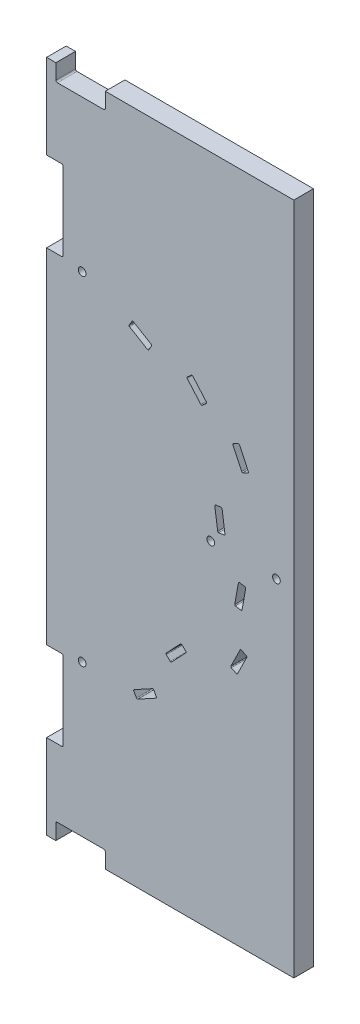
from build123d import *

# Parameters (mm, degrees)
SKETCH1_W                = 160
SKETCH1_H                = 436
BOSS_EXTRUDE1_DEPTH      = 12.7
CUT_EXTRUDE1_DEPTH       = 366.47051465
CIRPATTERN1_COUNT        = 3
CIRPATTERN1_ANGLE        = 102.52
CUT_EXTRUDE2_DEPTH       = 366.47051465
CIRPATTERN2_COUNT        = 2
CIRPATTERN2_ANGLE        = 51.26
F_5_0_5_DIAMETER_HOLE1_D = 5
CUT_EXTRUDE3_DEPTH       = 366.47051465


with BuildPart() as part:
    # Sketch1 → Boss-Extrude1 (new body)
    with BuildSketch(Plane.XY):
        with Locations((74.181489842, 113.112481294)):
            Rectangle(SKETCH1_W, SKETCH1_H)
    extrude(amount=BOSS_EXTRUDE1_DEPTH)

    # Sketch3 → Cut-Extrude1 (cut, through all)
    with BuildSketch(Plane(origin=(0, 0, 0), x_dir=(-1, 0, 0), z_dir=(0, 0, -1))):
        with BuildLine():
            Line((-59.468207995, 200.039680409), (-47.878421887, 206.962603057))
            ThreePointArc((-47.878421887, 206.962603057), (-47.604309032, 207.331039293), (-47.671005734, 207.785390113))
            Line((-47.671005734, 207.785390113), (-49.508913494, 210.862263699))
            ThreePointArc((-49.508913494, 210.862263699), (-49.87734973, 211.136376554), (-50.33170055, 211.069679852))
            Line((-50.33170055, 211.069679852), (-61.921486657, 204.146757205))
            ThreePointArc((-61.921486657, 204.146757205), (-62.195599513, 203.778320969), (-62.128902811, 203.323970149))
            Line((-62.128902811, 203.323970149), (-60.29099505, 200.247096563))
            ThreePointArc((-60.29099505, 200.247096563), (-59.922558815, 199.972983708), (-59.468207995, 200.039680409))
        make_face()
        with BuildLine():
            Line((-94.041533827, 186.486629291), (-85.165935337, 196.658834137))
            ThreePointArc((-85.165935337, 196.658834137), (-85.019418624, 197.094053588), (-85.223562287, 197.505403175))
            Line((-85.223562287, 197.505403175), (-87.924094299, 199.861710211))
            ThreePointArc((-87.924094299, 199.861710211), (-88.35931375, 200.008226924), (-88.770663336, 199.804083262))
            Line((-88.770663336, 199.804083262), (-97.646261826, 189.631878415))
            ThreePointArc((-97.646261826, 189.631878415), (-97.79277854, 189.196658964), (-97.588634877, 188.785309377))
            Line((-97.588634877, 188.785309377), (-94.888102864, 186.429002341))
            ThreePointArc((-94.888102864, 186.429002341), (-94.452883414, 186.282485628), (-94.041533827, 186.486629291))
        make_face()
    cut_extrude1 = extrude(amount=-CUT_EXTRUDE1_DEPTH, mode=Mode.SUBTRACT)

    # CirPattern1: Cut-Extrude1 ×3 about axis
    cirpattern1_axis = Axis((-0.318510158, 113.112481294, 0), (0, 0, -1))
    for i in range(1, CIRPATTERN1_COUNT):
        add(cut_extrude1.rotate(cirpattern1_axis, i * CIRPATTERN1_ANGLE / (CIRPATTERN1_COUNT - 1)), mode=Mode.SUBTRACT)

    # Sketch4 → Cut-Extrude2 (cut, through all)
    with BuildSketch(Plane(origin=(0, 0, 0), x_dir=(-1, 0, 0), z_dir=(0, 0, -1))):
        with BuildLine():
            Line((-124.50767277, 163.337281817), (-121.260766753, 161.81983089))
            ThreePointArc((-121.260766753, 161.81983089), (-120.80200107, 161.799406266), (-120.463162354, 162.109360202))
            Line((-120.463162354, 162.109360202), (-114.747317623, 174.339614451))
            ThreePointArc((-114.747317623, 174.339614451), (-114.726892999, 174.798380135), (-115.036846934, 175.13721885))
            Line((-115.036846934, 175.13721885), (-118.283752952, 176.654669778))
            ThreePointArc((-118.283752952, 176.654669778), (-118.742518635, 176.675094401), (-119.081357351, 176.365140466))
            Line((-119.081357351, 176.365140466), (-124.797202082, 164.134886216))
            ThreePointArc((-124.797202082, 164.134886216), (-124.817626706, 163.676120533), (-124.50767277, 163.337281817))
        make_face()
    cut_extrude2 = extrude(amount=-CUT_EXTRUDE2_DEPTH, mode=Mode.SUBTRACT)

    # CirPattern2: Cut-Extrude2 ×2 about axis
    cirpattern2_axis = Axis((-0.318510158, 113.112481294, 0), (0, 0, -1))
    for i in range(1, CIRPATTERN2_COUNT):
        add(cut_extrude2.rotate(cirpattern2_axis, i * CIRPATTERN2_ANGLE / (CIRPATTERN2_COUNT - 1)), mode=Mode.SUBTRACT)

    # Ø5.0 (5) Diameter Hole1 (through all)
    with Locations(Plane(origin=(0, 0, 0), x_dir=(-1, 0, 0), z_dir=(0, 0, -1))):
        with Locations((-142.931489842, 113.112481294)):
            f_5_0_5_diameter_hole1 = Hole(F_5_0_5_DIAMETER_HOLE1_D / 2)

    # Sketch-Pattern9: Ø5.0 (5) Diameter Hole1 at 3 more places
    with Locations((-42.5, 0, 0), (-125.75, 109.358642, 0), (-125.75, -109.358642, 0)):
        add(f_5_0_5_diameter_hole1, mode=Mode.SUBTRACT)

    # Sketch9 → Cut-Extrude3 (cut, through all)
    with BuildSketch(Plane(origin=(0, 0, 0), x_dir=(-1, 0, 0), z_dir=(0, 0, -1))):
        with BuildLine():
            Line((5.818510158, 276.362481294), (-3.931489842, 276.362481294))
            ThreePointArc((-3.931489842, 276.362481294), (-4.638596623, 276.069588075), (-4.931489842, 275.362481294))
            Line((-4.931489842, 275.362481294), (-4.931489842, 225.362481294))
            ThreePointArc((-4.931489842, 225.362481294), (-4.638596623, 224.655374512), (-3.931489842, 224.362481294))
            Line((-3.931489842, 224.362481294), (5.818510158, 224.362481294))
            Line((5.818510158, 224.362481294), (5.818510158, 276.362481294))
        make_face()
        with BuildLine():
            Line((-32.181489842, 331.112481294), (-0.181489842, 331.112481294))
            Line((-0.181489842, 331.112481294), (-0.181489842, 321.362481294))
            ThreePointArc((-0.181489842, 321.362481294), (-0.474383061, 320.655374512), (-1.181489842, 320.362481294))
            Line((-1.181489842, 320.362481294), (-31.181489842, 320.362481294))
            ThreePointArc((-31.181489842, 320.362481294), (-31.888596623, 320.655374512), (-32.181489842, 321.362481294))
            Line((-32.181489842, 321.362481294), (-32.181489842, 331.112481294))
        make_face()
    cut_extrude3 = extrude(amount=-CUT_EXTRUDE3_DEPTH, mode=Mode.SUBTRACT)

    # Mirror1: Cut-Extrude3 across plane
    add(cut_extrude3.mirror(Plane.ZX.offset(113.112481294)), mode=Mode.SUBTRACT)


solid = part.part
